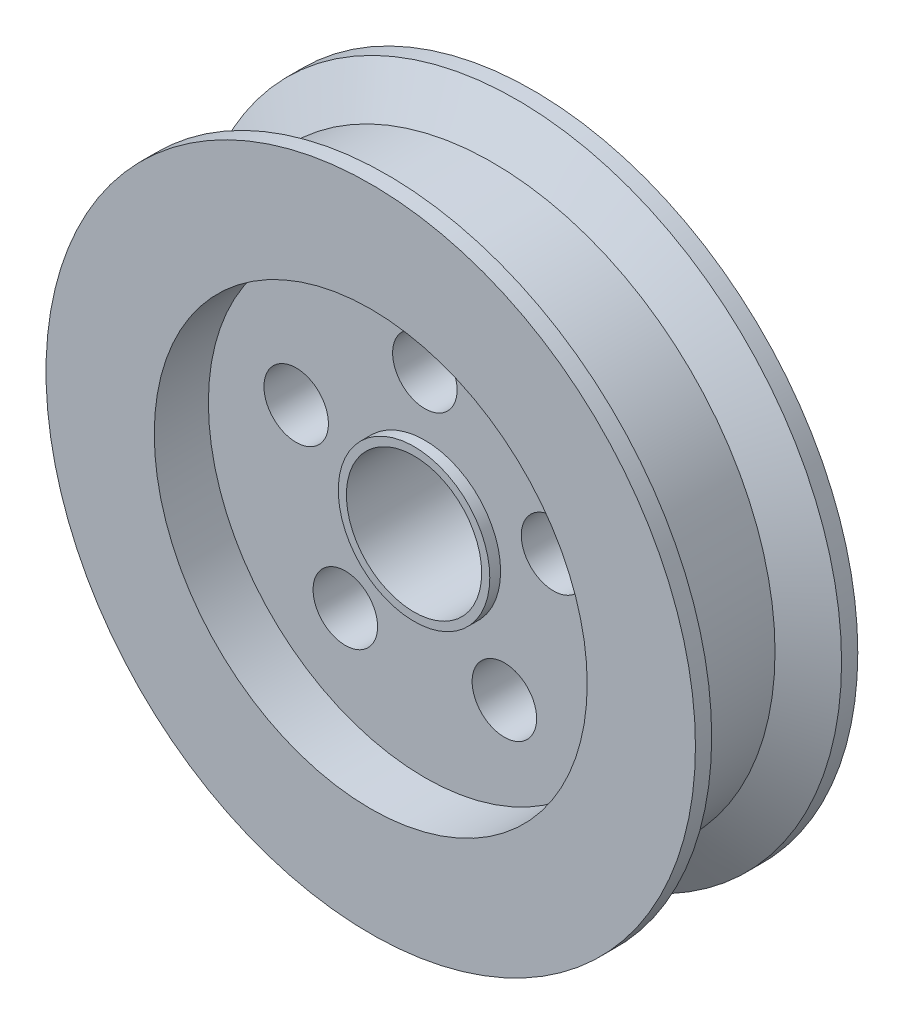
from build123d import *

# Parameters (mm, degrees)
SKETCH1_R                = 60
SKETCH1_R_2              = 12.5
BOSS_EXTRUDE2_DEPTH      = 30
SKETCH3_R                = 40
CUT_EXTRUDE3_DEPTH       = 10
SKETCH4_R                = 5.959098303
CUT_EXTRUDE4_DEPTH       = 21
SKETCH7_R                = 14
SKETCH7_R_2              = 12.5
BOSS_EXTRUDE6_DEPTH      = 2
BOSS_EXTRUDE6_DEPTH_BACK = 7


with BuildPart() as part:
    # Sketch1 → Boss-Extrude2 (new body)
    with BuildSketch(Plane.XY):
        Circle(SKETCH1_R)
        Circle(SKETCH1_R_2, mode=Mode.SUBTRACT)
    extrude(amount=BOSS_EXTRUDE2_DEPTH)

    # Sketch3 → Cut-Extrude3 (cut)
    with BuildSketch(Plane.XY.offset(30)):
        Circle(SKETCH3_R)
    cut_extrude3 = extrude(amount=-CUT_EXTRUDE3_DEPTH, mode=Mode.SUBTRACT)

    # Mirror6: Cut-Extrude3 across plane
    add(cut_extrude3.mirror(Plane.XY), mode=Mode.SUBTRACT)

    # Sketch4 → Cut-Extrude4 (cut, through all)
    with BuildSketch(Plane.XY.offset(20)):
        with Locations((0, 25)):
            Circle(SKETCH4_R)
        with Locations((23.776412907, 7.725424859)):
            Circle(SKETCH4_R)
        with Locations((14.694631307, -20.225424859)):
            Circle(SKETCH4_R)
        with Locations((-14.694631307, -20.225424859)):
            Circle(SKETCH4_R)
        with Locations((-23.776412907, 7.725424859)):
            Circle(SKETCH4_R)
    extrude(amount=-CUT_EXTRUDE4_DEPTH, mode=Mode.SUBTRACT)

    # Sketch6 → Cut-Revolve1 (revolve, cut)
    with BuildSketch(Plane(origin=(0, 0, 0), x_dir=(1, 0, 0), z_dir=(0, 1, 0))):
        Polygon((60, -3), (52.205771366, -7.5), (52.205771366, -22.5), (60, -27), align=None)
    revolve(axis=Axis((0, 0, 0), (0, 0, -1)), mode=Mode.SUBTRACT)

    # Sketch7 → Boss-Extrude6 (add, two sides)
    with BuildSketch(Plane.XY.offset(20)) as boss_extrude6_sk:
        Circle(SKETCH7_R)
        Circle(SKETCH7_R_2, mode=Mode.SUBTRACT)
    extrude(amount=BOSS_EXTRUDE6_DEPTH)
    extrude(boss_extrude6_sk.sketch, amount=-BOSS_EXTRUDE6_DEPTH_BACK)


solid = part.part
